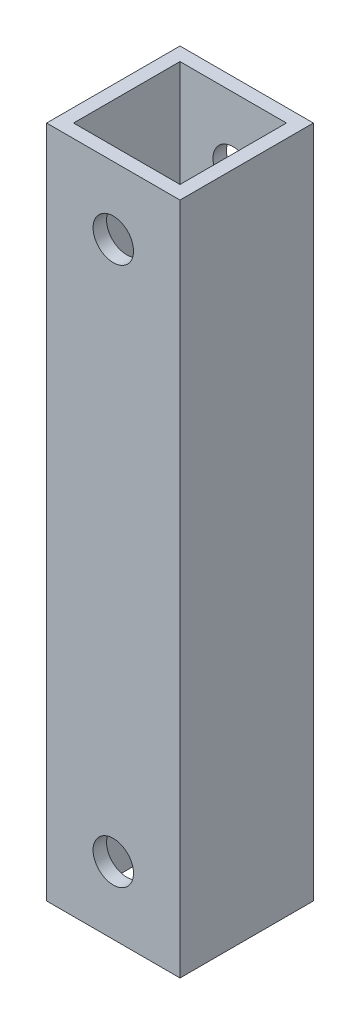
from build123d import *

# Parameters (mm, degrees)
SKETCH_1_W         = 9.9
SKETCH_1_H         = 9.9
SKETCH_1_W_2       = 7.9
SKETCH_1_H_2       = 7.9
EXTRUDE_1_DEPTH    = 50
SKETCH2_R          = 1.5
CUT_EXTRUDE2_DEPTH = 10.9


with BuildPart() as part:
    # Эскиз1 → Бобышка-Вытянуть1 (new body)
    with BuildSketch(Plane(origin=(0, 0, 0), x_dir=(1, 0, 0), z_dir=(0, 1, 0))):
        Rectangle(SKETCH_1_W, SKETCH_1_H)
        Rectangle(SKETCH_1_W_2, SKETCH_1_H_2, mode=Mode.SUBTRACT)
    extrude(amount=EXTRUDE_1_DEPTH)

    # Sketch2 → Cut-Extrude2 (cut, through all)
    with BuildSketch(Plane(origin=(0, 0, -4.95), x_dir=(-1, 0, 0), z_dir=(0, 0, -1))):
        with Locations((0, 45)):
            Circle(SKETCH2_R)
        with Locations((0, 5)):
            Circle(SKETCH2_R)
    extrude(amount=-CUT_EXTRUDE2_DEPTH, mode=Mode.SUBTRACT)


solid = part.part
